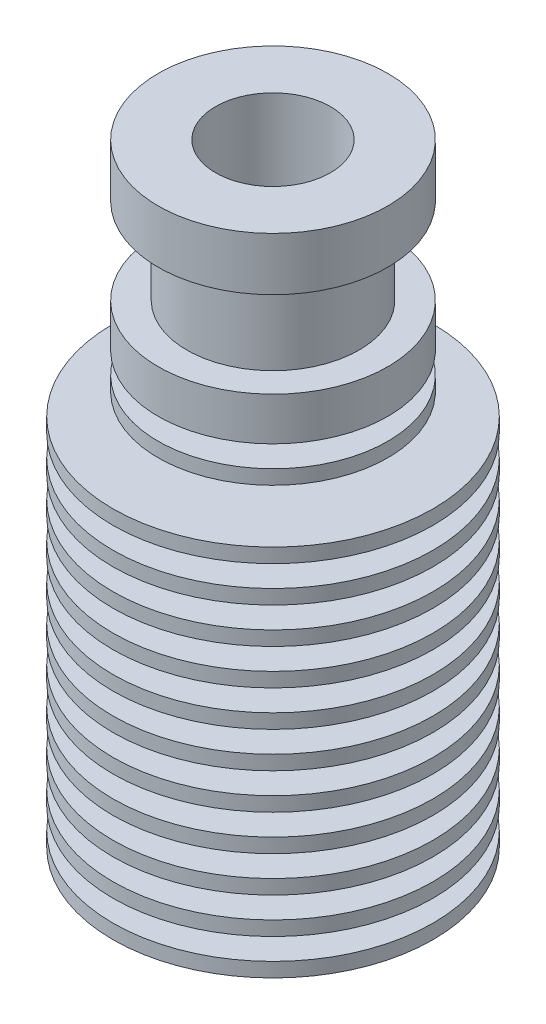
from build123d import *


with BuildPart() as part:
    # Sketch1 → Revolve1 (revolve)
    with BuildSketch(Plane.XY):
        Polygon((11.15, 18.5), (5.082863863, 18.5), (5.082863863, 20), (11.15, 20), (11.15, 21), (4.951844414, 21), (4.951844414, 22.5), (11.15, 22.5), (11.15, 23.5), (4.820824966, 23.5), (4.820824966, 25), (11.15, 25), (11.15, 26), (4.689805518, 26), (4.689805518, 27.5), (8, 27.5), (8, 28.5), (4.689805518, 28.5), (4.689805518, 30), (8, 30), (8, 33), (6, 33), (6, 39), (8, 39), (8, 42.7), (4, 42.7), (4, 36.6), (2.1, 34.7), (2.1, 14.7), (3.5, 13.3), (3.5, 0), (11.15, 0), (11.15, 1), (6, 1), (6, 2.5), (11.15, 2.5), (11.15, 3.5), (5.868980552, 3.5), (5.868980552, 5), (11.15, 5), (11.15, 6), (5.737961104, 6), (5.737961104, 7.5), (11.15, 7.5), (11.15, 8.5), (5.606941655, 8.5), (5.606941655, 10), (11.15, 10), (11.15, 11), (5.475922207, 11), (5.475922207, 12.5), (11.15, 12.5), (11.15, 13.5), (5.344902759, 13.5), (5.344902759, 15), (11.15, 15), (11.15, 16), (5.213883311, 16), (5.213883311, 17.5), (11.15, 17.5), align=None)
    revolve(axis=Axis((0, 42.7, 0), (0, -1, 0)))


solid = part.part
